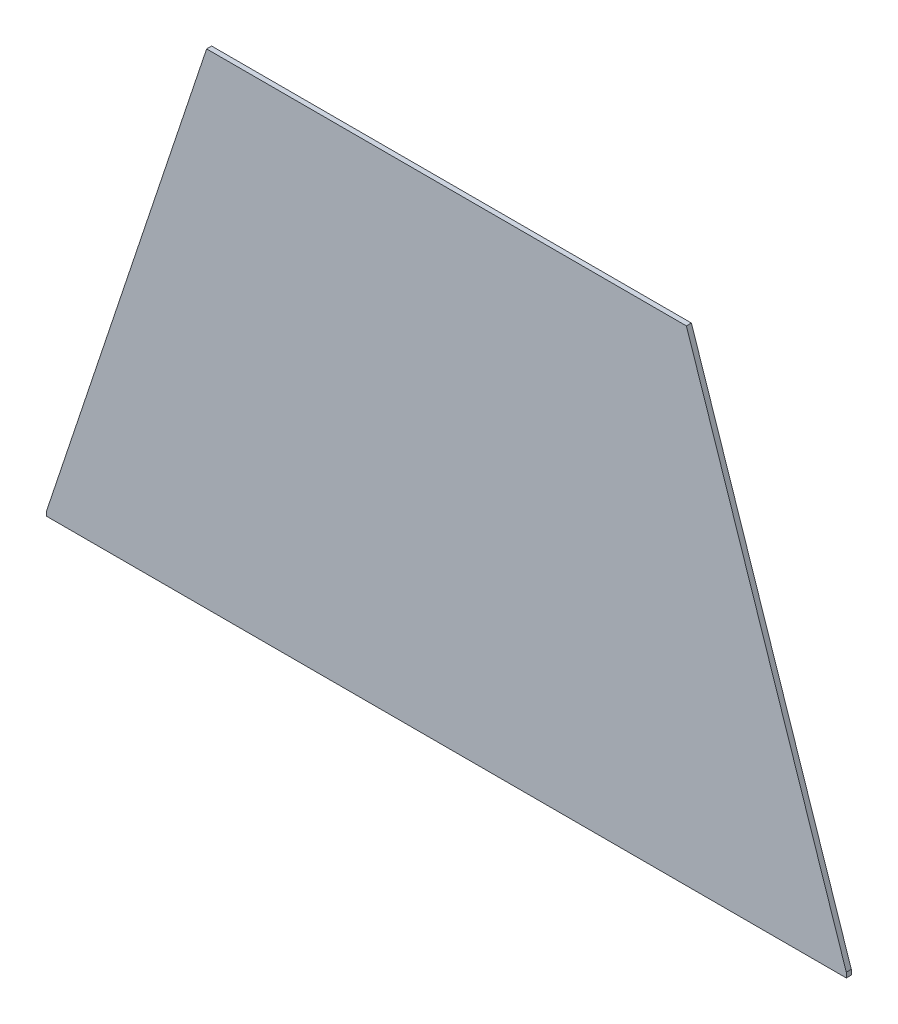
from build123d import *

# Parameters (mm, degrees)
BOSS_EXTRUDE1_DEPTH = 1.5875


with BuildPart() as part:
    # Sketch2 → Boss-Extrude1 (new body)
    with BuildSketch(Plane.XY):
        Polygon((-127, 0), (-76.2, 152.4), (76.2, 152.4), (127, 0), (127, -1.5875), (-127, -1.5875), align=None)
    extrude(amount=BOSS_EXTRUDE1_DEPTH)


solid = part.part
